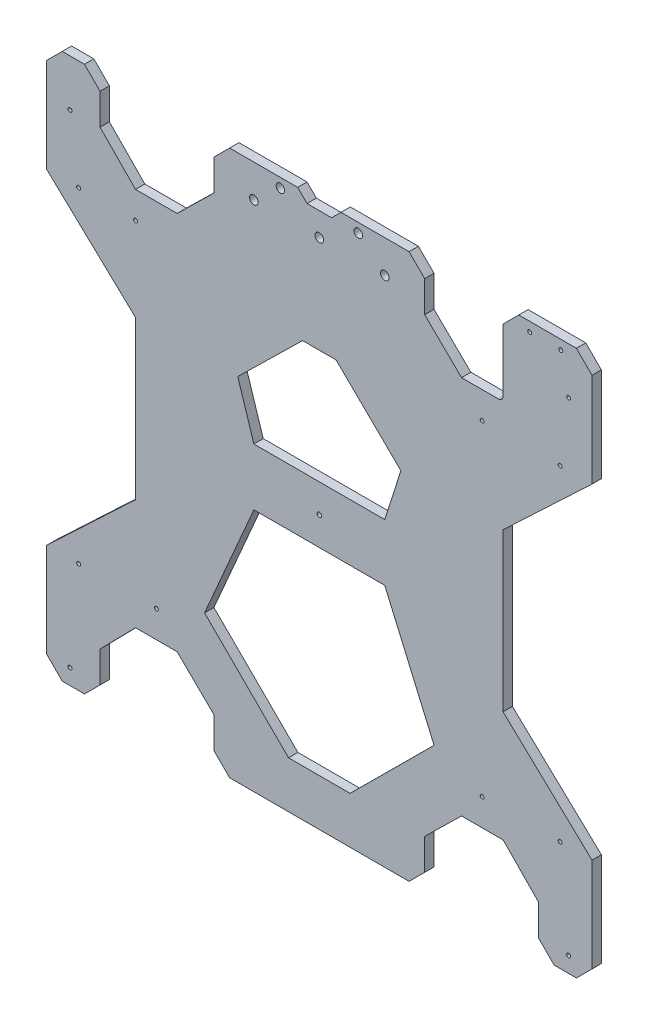
from build123d import *

# Parameters (mm, degrees)
SCHIZZO13_R                  = 1.25
SCHIZZO13_R_2                = 1.5
SCHIZZO13_R_3                = 2.75
ESTRUSIONE_ESTRUSIONE2_DEPTH = 6


with BuildPart() as part:
    # Schizzo13 → Estrusione-Estrusione2 (new body)
    with BuildSketch(Plane.XY):
        with BuildLine():
            Line((10, 0), (24.28195797, 0))
            Line((24.28195797, 0), (34.28195797, 10))
            Line((34.28195797, 10), (34.28195797, 30))
            Line((34.28195797, 30), (57.017366293, 53.192694567))
            Line((57.017366293, 53.192694567), (83.745372993, 53.192694567))
            Line((83.745372993, 53.192694567), (107.404551383, 30))
            Line((107.404551383, 30), (107.404551383, 10))
            Line((107.404551383, 10), (117.404551383, 0))
            Line((117.404551383, 0), (232.595448617, 0))
            Line((232.595448617, 0), (242.595448617, 10))
            Line((242.595448617, 10), (242.595448617, 30))
            Line((242.595448617, 30), (266.254627007, 53.192694567))
            Line((266.254627007, 53.192694567), (292.982633707, 53.192694567))
            Line((292.982633707, 53.192694567), (315.71804203, 30))
            Line((315.71804203, 30), (315.71804203, 10))
            Line((315.71804203, 10), (325.71804203, 0))
            Line((325.71804203, 0), (340, 0))
            Line((340, 0), (350, 10))
            Line((350, 10), (350, 70.5))
            Line((350, 70.5), (292.919241786, 124.388863529))
            Line((292.919241786, 124.388863529), (292.919241786, 225.611136471))
            Line((292.919241786, 225.611136471), (350, 279.5))
            Line((350, 279.5), (350, 340))
            Line((350, 340), (340, 350))
            Line((340, 350), (302.982633707, 350))
            Line((302.982633707, 350), (292.982633707, 340))
            Line((292.982633707, 340), (292.982633707, 299.807305433))
            ThreePointArc((292.982633707, 299.807305433), (292.103954051, 297.685985089), (289.982633707, 296.807305433))
            Line((289.982633707, 296.807305433), (266.254627007, 296.807305433))
            Line((266.254627007, 296.807305433), (242.595448617, 320))
            Line((242.595448617, 320), (242.595448617, 340))
            Line((242.595448617, 340), (232.595448617, 350))
            Line((232.595448617, 350), (188.89112909, 350))
            Line((188.89112909, 350), (182.89112909, 344))
            Line((182.89112909, 344), (167.10887091, 344))
            Line((167.10887091, 344), (161.10887091, 350))
            Line((161.10887091, 350), (117.404551383, 350))
            Line((117.404551383, 350), (107.404551383, 340))
            Line((107.404551383, 340), (107.404551383, 320))
            Line((107.404551383, 320), (83.745372993, 296.807305433))
            Line((83.745372993, 296.807305433), (57.017366293, 296.807305433))
            Line((57.017366293, 296.807305433), (34.28195797, 320))
            Line((34.28195797, 320), (34.28195797, 340))
            Line((34.28195797, 340), (24.28195797, 350))
            Line((24.28195797, 350), (10, 350))
            Line((10, 350), (0, 340))
            Line((0, 340), (0, 279.5))
            Line((0, 279.5), (57.080758214, 225.611136471))
            Line((57.080758214, 225.611136471), (57.080758214, 175))
            Line((57.080758214, 175), (57.080758214, 124.388863529))
            Line((57.080758214, 124.388863529), (0, 70.5))
            Line((0, 70.5), (0, 10))
            Line((0, 10), (10, 0))
        make_face()
        with Locations((15, 320)):
            Circle(SCHIZZO13_R, mode=Mode.SUBTRACT)
        with Locations((20.5, 279.5)):
            Circle(SCHIZZO13_R, mode=Mode.SUBTRACT)
        with Locations((57.080758214, 279.5)):
            Circle(SCHIZZO13_R, mode=Mode.SUBTRACT)
        with Locations((175, 175)):
            Circle(SCHIZZO13_R_2, mode=Mode.SUBTRACT)
        with Locations((20.5, 70.5)):
            Circle(SCHIZZO13_R, mode=Mode.SUBTRACT)
        with Locations((200, 344)):
            Circle(SCHIZZO13_R_3, mode=Mode.SUBTRACT)
        with Locations((150, 344)):
            Circle(SCHIZZO13_R_3, mode=Mode.SUBTRACT)
        with Locations((175, 329)):
            Circle(SCHIZZO13_R_3, mode=Mode.SUBTRACT)
        with Locations((217, 329)):
            Circle(SCHIZZO13_R_3, mode=Mode.SUBTRACT)
        with Locations((133, 329)):
            Circle(SCHIZZO13_R_3, mode=Mode.SUBTRACT)
        with Locations((70.5, 70.5)):
            Circle(SCHIZZO13_R, mode=Mode.SUBTRACT)
        with Locations((279.5, 70.5)):
            Circle(SCHIZZO13_R, mode=Mode.SUBTRACT)
        with Locations((329.5, 70.5)):
            Circle(SCHIZZO13_R, mode=Mode.SUBTRACT)
        with Locations((335, 10)):
            Circle(SCHIZZO13_R, mode=Mode.SUBTRACT)
        with Locations((15, 10)):
            Circle(SCHIZZO13_R, mode=Mode.SUBTRACT)
        with Locations((279.5, 279.5)):
            Circle(SCHIZZO13_R, mode=Mode.SUBTRACT)
        with Locations((329.5, 279.5)):
            Circle(SCHIZZO13_R, mode=Mode.SUBTRACT)
        with Locations((335, 320)):
            Circle(SCHIZZO13_R, mode=Mode.SUBTRACT)
        with Locations((310, 344)):
            Circle(SCHIZZO13_R, mode=Mode.SUBTRACT)
        with Locations((330, 344)):
            Circle(SCHIZZO13_R, mode=Mode.SUBTRACT)
        Polygon((217, 193.286910978), (227.343033378, 225.611136471), (185.750894453, 266.383210572), (164.249105547, 266.383210572), (122.656966622, 225.611136471), (133, 193.286910978), align=None, mode=Mode.SUBTRACT)
        Polygon((133, 156.713089022), (101.348199345, 83.616789428), (155.254193112, 30), (194.745806888, 30), (248.651800655, 83.616789428), (217, 156.713089022), align=None, mode=Mode.SUBTRACT)
    extrude(amount=-ESTRUSIONE_ESTRUSIONE2_DEPTH)


solid = part.part
